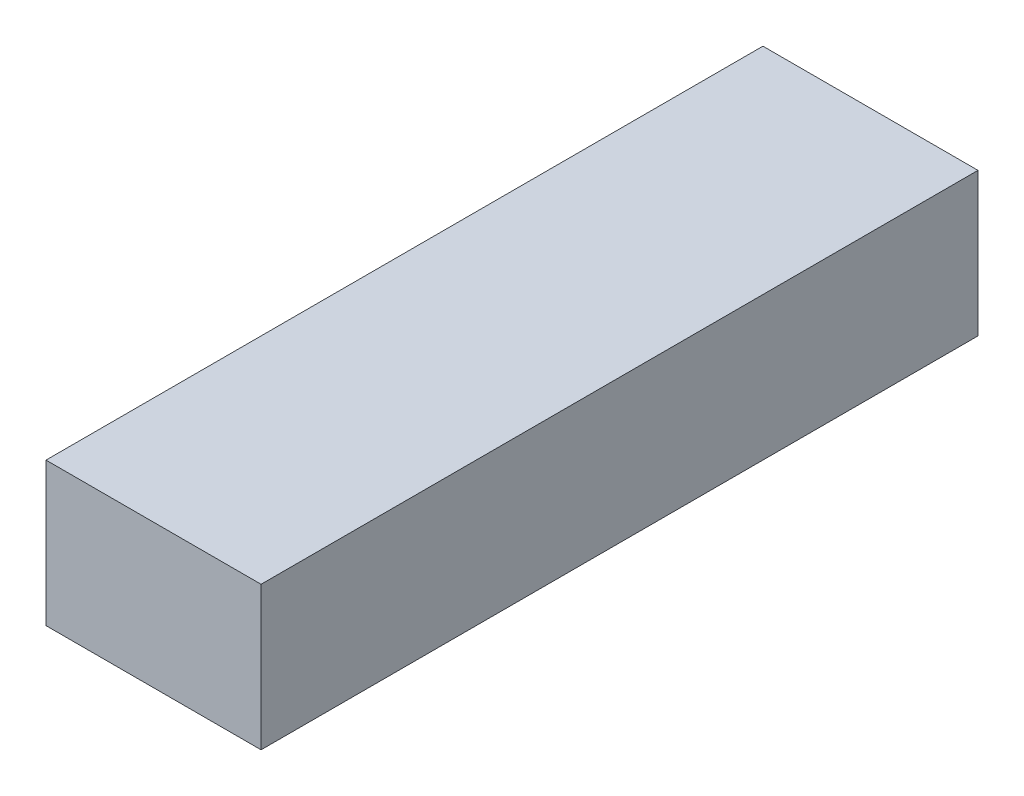
from build123d import *

# Parameters (mm, degrees)
SKETCH_1_W      = 20
SKETCH_1_H      = 4
EXTRUDE_1_DEPTH = 6


with BuildPart() as part:
    # Эскиз1 → Бобышка-Вытянуть1 (new body)
    with BuildSketch(Plane(origin=(0, 0, 0), x_dir=(0, 0, -1), z_dir=(1, 0, 0))):
        with Locations((10, 2)):
            Rectangle(SKETCH_1_W, SKETCH_1_H)
    extrude(amount=EXTRUDE_1_DEPTH)


solid = part.part
